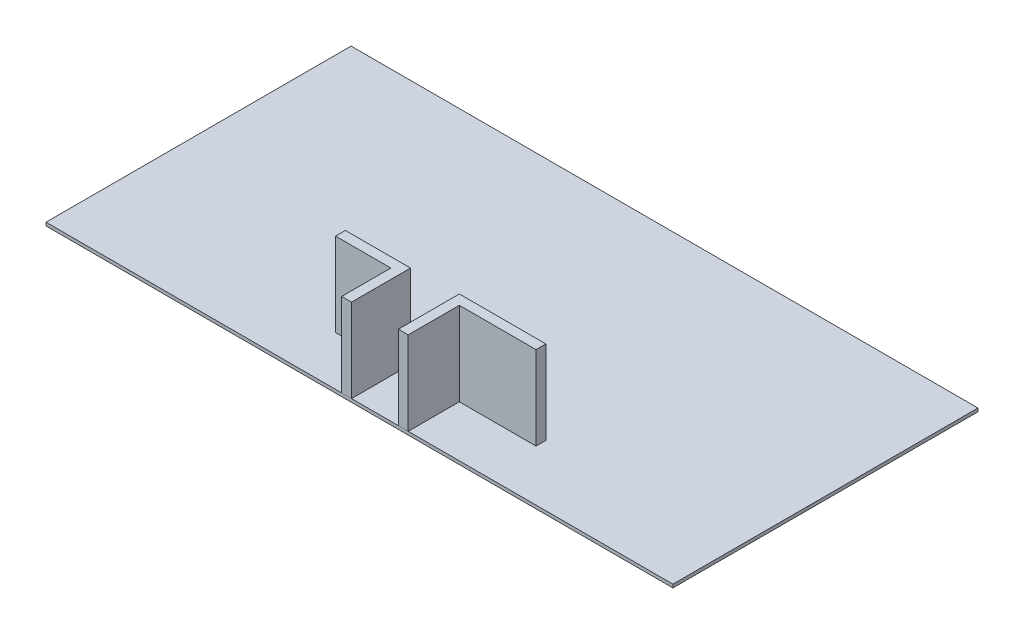
from build123d import *

# Parameters (mm, degrees)
BOSS_EXTRUDE1_DEPTH   = 2550
BOSS_EXTRUDE1_2_DEPTH = 2550
SKETCH2_W             = 19131.32997412
SKETCH2_H             = 9309.604753216
BOSS_EXTRUDE2_DEPTH   = 100


with BuildPart() as part:
    # Sketch1 → Boss-Extrude1 (new body)
    with BuildSketch(Plane(origin=(0, 0, 0), x_dir=(1, 0, 0), z_dir=(0, 1, 0))):
        Polygon((300, 0), (-1687.597138015, 0), (-1687.597138015, -300), (0, -300), (0, -1800), (300, -1800), align=None)
    extrude(amount=BOSS_EXTRUDE1_DEPTH)


with BuildPart() as body_2:
    # Sketch1 → Boss-Extrude1 2 (new body)
    with BuildSketch(Plane(origin=(0, 0, 0), x_dir=(1, 0, 0), z_dir=(0, 1, 0))):
        Polygon((1730, 60), (4369.564447806, 60), (4369.564447806, -240), (2030, -240), (2030, -1800), (1730, -1800), align=None)
    extrude(amount=BOSS_EXTRUDE1_2_DEPTH)


with BuildPart() as body_3:
    # Sketch2 → Boss-Extrude2 (new body)
    with BuildSketch(Plane.XZ):
        with Locations((541.921421212, -2854.802376608)):
            Rectangle(SKETCH2_W, SKETCH2_H)
    extrude(amount=BOSS_EXTRUDE2_DEPTH)


solid = Compound([part.part, body_2.part, body_3.part])
